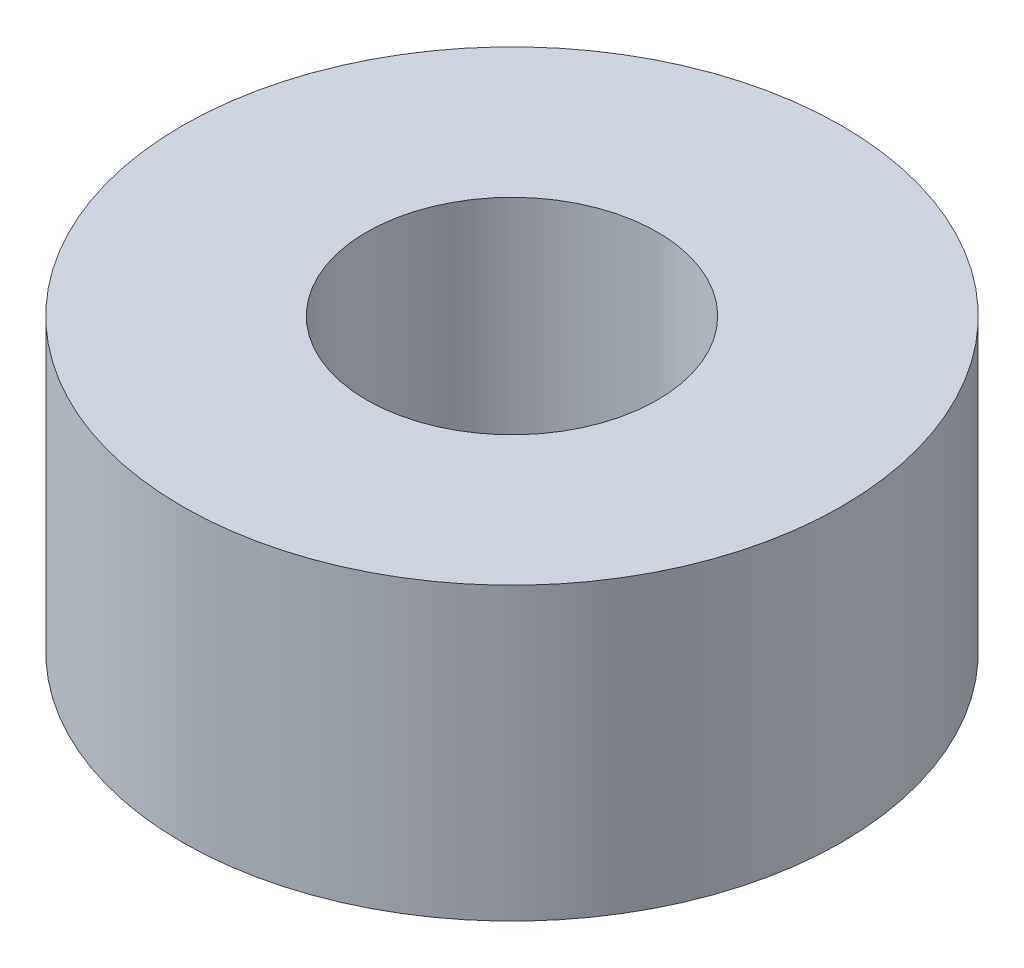
from build123d import *

# Parameters (mm, degrees)
SKETCH1_R           = 3.4
SKETCH1_R_2         = 1.5
SPACER_HEIGHT_DEPTH = 3


with BuildPart() as part:
    # Sketch1 → Spacer Height (new body)
    with BuildSketch(Plane(origin=(0, 0, 0), x_dir=(1, 0, 0), z_dir=(0, 1, 0))):
        Circle(SKETCH1_R)
        Circle(SKETCH1_R_2, mode=Mode.SUBTRACT)
    extrude(amount=SPACER_HEIGHT_DEPTH)


solid = part.part
